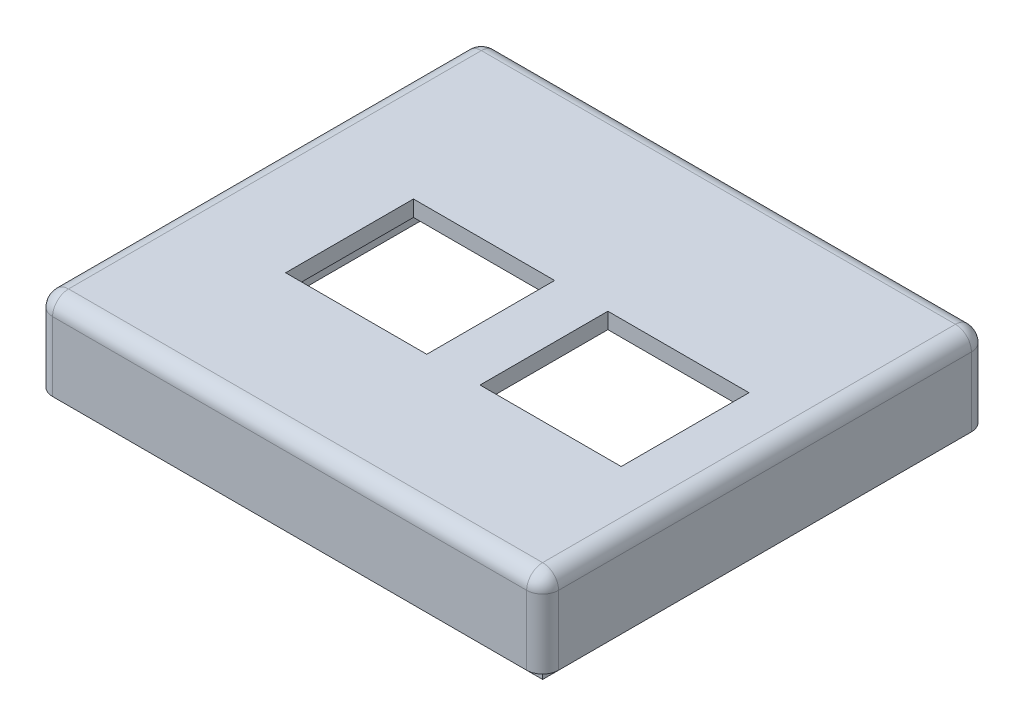
from build123d import *

# Parameters (mm, degrees)
SKETCH1_W           = 95
SKETCH1_H           = 83.5
SKETCH1_W_2         = 89
SKETCH1_H_2         = 77.5
SKETCH1_W_3         = 83
SKETCH1_H_3         = 71.5
BOSS_EXTRUDE1_DEPTH = 3
SKETCH1_4_W         = 95
SKETCH1_4_H         = 83.5
SKETCH1_4_W_2       = 89
SKETCH1_4_H_2       = 77.5
SKETCH1_4_W_3       = 83
SKETCH1_4_H_3       = 71.5
BOSS_EXTRUDE2_DEPTH = 16
SKETCH1_5_W         = 89
SKETCH1_5_H         = 77.5
SKETCH1_5_W_2       = 83
SKETCH1_5_H_2       = 71.5
BOSS_EXTRUDE3_DEPTH = 19
FILLET1_R           = 3
SKETCH3_W           = 6
SKETCH3_H           = 6
CUT_EXTRUDE1_DEPTH  = 6
CUT_EXTRUDE2_REACH  = 5
SKETCH4_W           = 26.5
SKETCH4_H           = 24


with BuildPart() as part:
    # Sketch1 → Boss-Extrude1 (new body)
    with BuildSketch(Plane(origin=(0, 0, 0), x_dir=(1, 0, 0), z_dir=(0, 1, 0))):
        Rectangle(SKETCH1_W, SKETCH1_H)
        Rectangle(SKETCH1_W_2, SKETCH1_H_2, mode=Mode.SUBTRACT)
        Rectangle(SKETCH1_W_2, SKETCH1_H_2)
        Rectangle(SKETCH1_W_3, SKETCH1_H_3, mode=Mode.SUBTRACT)
        Rectangle(SKETCH1_W_3, SKETCH1_H_3)
    extrude(amount=-BOSS_EXTRUDE1_DEPTH)

    # Sketch1_4 → Boss-Extrude2 (add)
    with BuildSketch(Plane(origin=(0, 0, 0), x_dir=(1, 0, 0), z_dir=(0, 1, 0))):
        Rectangle(SKETCH1_4_W, SKETCH1_4_H)
        Rectangle(SKETCH1_4_W_2, SKETCH1_4_H_2, mode=Mode.SUBTRACT)
        Rectangle(SKETCH1_4_W_2, SKETCH1_4_H_2)
        Rectangle(SKETCH1_4_W_3, SKETCH1_4_H_3, mode=Mode.SUBTRACT)
    extrude(amount=-BOSS_EXTRUDE2_DEPTH)

    # Sketch1_5 → Boss-Extrude3 (add)
    with BuildSketch(Plane(origin=(0, 0, 0), x_dir=(1, 0, 0), z_dir=(0, 1, 0))):
        Rectangle(SKETCH1_5_W, SKETCH1_5_H)
        Rectangle(SKETCH1_5_W_2, SKETCH1_5_H_2, mode=Mode.SUBTRACT)
    extrude(amount=-BOSS_EXTRUDE3_DEPTH)

    # Fillet1
    fillet1_edges = [part.edges().sort_by_distance(p)[0] for p in [
        (-47.5, 0, 0),
        (0, 0, -41.75),
        (47.5, 0, 0),
        (0, 0, 41.75),
        (-47.5, -8, 41.75),
        (-47.5, -8, -41.75),
        (47.5, -8, -41.75),
        (47.5, -8, 41.75),
    ]]
    fillet(fillet1_edges, radius=FILLET1_R)

    # Sketch3 → Cut-Extrude1 (cut)
    with BuildSketch(Plane(origin=(47.5, 0, 0), x_dir=(0, 0, -1), z_dir=(1, 0, 0))):
        with Locations((-32.75, -19)):
            Rectangle(SKETCH3_W, SKETCH3_H)
        with Locations((1.25, -19)):
            Rectangle(SKETCH3_W, SKETCH3_H)
    extrude(amount=-CUT_EXTRUDE1_DEPTH, mode=Mode.SUBTRACT)

    # Sketch4 → Cut-Extrude2 (cut, up to next)
    with BuildSketch(Plane.XZ.offset(3), mode=Mode.PRIVATE) as cut_extrude2_sk1:
        with Locations((-13.5, 3.75)):
            Rectangle(SKETCH4_W, SKETCH4_H)
    cut_extrude2_tool1 = extrude(cut_extrude2_sk1.sketch, amount=-CUT_EXTRUDE2_REACH, mode=Mode.PRIVATE) & part.part
    add(cut_extrude2_tool1.solids().sort_by_distance((-13.5, -3, 3.75))[0], mode=Mode.SUBTRACT)
    # Sketch4 → Cut-Extrude2 (cut, up to next)
    with BuildSketch(Plane.XZ.offset(3), mode=Mode.PRIVATE) as cut_extrude2_sk2:
        with Locations((23, 3.75)):
            Rectangle(SKETCH4_W, SKETCH4_H)
    cut_extrude2_tool2 = extrude(cut_extrude2_sk2.sketch, amount=-CUT_EXTRUDE2_REACH, mode=Mode.PRIVATE) & part.part
    add(cut_extrude2_tool2.solids().sort_by_distance((23, -3, 3.75))[0], mode=Mode.SUBTRACT)


solid = part.part
